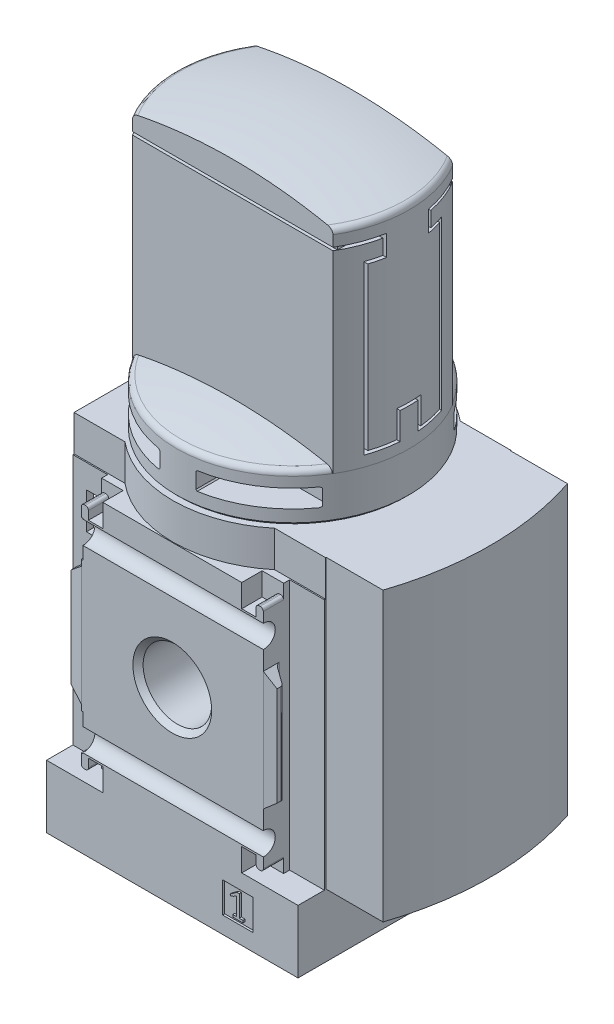
from build123d import *

# Parameters (mm, degrees)
BOSS_EXTRUDE1_DEPTH      = 48
BOSS_EXTRUDE2_DEPTH      = 20.1
BOSS_EXTRUDE2_DEPTH_BACK = 20.1
SKETCH2_W                = 42
SKETCH2_H                = 42
SKETCH3_W                = 42
SKETCH3_H                = 40.2
BOSS_EXTRUDE3_DEPTH      = 10.5
BOSS_EXTRUDE4_DEPTH      = 48
SKETCH7_W                = 5.1
SKETCH7_H                = 5.1
CUT_EXTRUDE1_DEPTH       = 0.35
SKETCH8_W                = 5.1
SKETCH8_H                = 5.1
CUT_EXTRUDE2_DEPTH       = 0.35
CUT_EXTRUDE3_DEPTH       = 25
CUT_EXTRUDE3_DEPTH_BACK  = 25
CUT_EXTRUDE4_DEPTH       = 25
CUT_EXTRUDE4_DEPTH_BACK  = 25
CUT_EXTRUDE5_DEPTH       = 3.4
CUT_EXTRUDE5_DEPTH_BACK  = 3.4
CUT_EXTRUDE6_DEPTH       = 3.4
CUT_EXTRUDE6_DEPTH_BACK  = 3.4
CUT_EXTRUDE7_DEPTH       = 3.4
CUT_EXTRUDE7_DEPTH_BACK  = 3.4
CUT_EXTRUDE8_DEPTH       = 3.4
CUT_EXTRUDE8_DEPTH_BACK  = 3.4
CUT_EXTRUDE9_DEPTH       = 21
CUT_EXTRUDE9_DEPTH_BACK  = 21
CUT_EXTRUDE10_DEPTH      = 21
CUT_EXTRUDE10_DEPTH_BACK = 21
CUT_EXTRUDE11_DEPTH      = 19.5
CUT_EXTRUDE11_DEPTH_BACK = 19.5
CUT_EXTRUDE12_DEPTH      = 10
CUT_EXTRUDE13_DEPTH      = 10
CUT_EXTRUDE14_DEPTH      = 10
CUT_EXTRUDE15_DEPTH      = 10
CUT_EXTRUDE16_DEPTH      = 20.5
SKETCH25_W               = 20
SKETCH25_H               = 0.5
CUT_EXTRUDE17_DEPTH      = 4.5
CUT_EXTRUDE18_DEPTH      = 22
CUT_EXTRUDE18_DEPTH_BACK = 22
SKETCH27_W               = 3.81
SKETCH27_H               = 6.07
CUT_EXTRUDE19_DEPTH      = 22
CUT_EXTRUDE19_DEPTH_BACK = 22
SKETCH28_W               = 3.81
SKETCH28_H               = 6.07
CUT_EXTRUDE20_DEPTH      = 11
CUT_EXTRUDE20_DEPTH_BACK = 11
SKETCH29_W               = 29
SKETCH29_H               = 37.9
BOSS_EXTRUDE5_DEPTH      = 19
BOSS_EXTRUDE5_DEPTH_BACK = 19
BOSS_EXTRUDE6_DEPTH      = 9
BOSS_EXTRUDE7_DEPTH      = 9
SKETCH33_R               = 3.05
BOSS_EXTRUDE8_DEPTH      = 5


with BuildPart() as part:
    # Sketch1 → Boss-Extrude1 (new body)
    with BuildSketch(Plane(origin=(0, 27, 0), x_dir=(1, 0, 0), z_dir=(0, 1, 0))):
        with BuildLine():
            Line((-21, -15.5), (-12.5, -15.5))
            ThreePointArc((-12.5, -15.5), (0, -20), (12.5, -15.5))
            Line((12.5, -15.5), (21, -15.5))
            Line((21, -15.5), (21, 15.5))
            Line((21, 15.5), (12.5, 15.5))
            ThreePointArc((12.5, 15.5), (0, 20), (-12.5, 15.5))
            Line((-12.5, 15.5), (-21, 15.5))
            Line((-21, 15.5), (-21, -15.5))
        make_face()
    extrude(amount=-BOSS_EXTRUDE1_DEPTH)

    # Sketch2 → Boss-Extrude2 (add, two sides: drawn at the far end of the back side and taken through both)
    with BuildSketch(Plane.XY.offset(-BOSS_EXTRUDE2_DEPTH_BACK)):
        Rectangle(SKETCH2_W, SKETCH2_H)
    extrude(amount=BOSS_EXTRUDE2_DEPTH + BOSS_EXTRUDE2_DEPTH_BACK)

    # Sketch3 → Boss-Extrude3 (add)
    with BuildSketch(Plane(origin=(0, -31.5, 0), x_dir=(1, 0, 0), z_dir=(0, 1, 0))):
        Rectangle(SKETCH3_W, SKETCH3_H)
    extrude(amount=BOSS_EXTRUDE3_DEPTH)

    # Sketch4 → Boss-Extrude4 (add)
    with BuildSketch(Plane(origin=(0, 27, 0), x_dir=(1, 0, 0), z_dir=(0, 1, 0))):
        with BuildLine():
            Line((20.9, -15.4), (30.5, -15.4))
            ThreePointArc((30.5, -15.4), (33, 0), (30.5, 15.4))
            Line((30.5, 15.4), (20.9, 15.4))
            Line((20.9, 15.4), (20.9, -15.4))
        make_face()
    extrude(amount=-BOSS_EXTRUDE4_DEPTH)

    # Sketch5 → Cut-Revolve1 (revolve, cut)
    with BuildSketch(Plane(origin=(0, 0, 0), x_dir=(0, 0, -1), z_dir=(1, 0, 0))):
        Polygon((-20.1, 0), (-20.1, 6.5785), (-19.244, 5.7225), (-7.799, 5.7225), (-6.943, 6.5785), (-6.943, 0), align=None)
    revolve(axis=Axis((0, 0, 6.943), (0, 0, 1)), mode=Mode.SUBTRACT)

    # Sketch6 → Cut-Revolve2 (revolve, cut)
    with BuildSketch(Plane(origin=(0, 0, 0), x_dir=(0, 0, -1), z_dir=(1, 0, 0))):
        Polygon((6.943, 0), (6.943, 6.5785), (7.799, 5.7225), (19.244, 5.7225), (20.1, 6.5785), (20.1, 0), align=None)
    revolve(axis=Axis((0, 0, -20.1), (0, 0, 1)), mode=Mode.SUBTRACT)

    # Sketch7 → Cut-Extrude1 (cut)
    with BuildSketch(Plane.XY.offset(20.1)):
        with Locations((10.95, -26.14)):
            Rectangle(SKETCH7_W, SKETCH7_H)
        Polygon((9.663200115, -25.02), (9.761292304, -25.275538889), (10.24, -25.062404491), (10.71, -24.78), (10.71, -27.76), (10.1, -27.76), (10.1, -28.14), (11.8, -28.14), (11.8, -27.76), (11.19, -27.76), (11.19, -24.21), (10.82, -24.21), align=None, mode=Mode.SUBTRACT)
    extrude(amount=-CUT_EXTRUDE1_DEPTH, mode=Mode.SUBTRACT)

    # Sketch8 → Cut-Extrude2 (cut)
    with BuildSketch(Plane.XY.offset(-20.1)):
        with Locations((-10.95, -26.14)):
            Rectangle(SKETCH8_W, SKETCH8_H)
        with BuildLine():
            Line((-12.03983262, -25.241503505), (-10.470570303, -27.482642356))
            ThreePointArc((-10.470570303, -27.482642356), (-10.463784424, -27.586174861), (-10.552485507, -27.64))
            Line((-10.552485507, -27.64), (-12.15, -27.64))
            Line((-12.15, -27.64), (-12.15, -28.14))
            Line((-12.15, -28.14), (-9.75, -28.14))
            Line((-9.75, -28.14), (-9.75, -27.64))
            Line((-9.75, -27.64), (-11.575165094, -25.033394109))
            ThreePointArc((-11.575165094, -25.033394109), (-11.592129791, -24.774562847), (-11.370377083, -24.64))
            Line((-11.370377083, -24.64), (-10.75, -24.64))
            ThreePointArc((-10.75, -24.64), (-10.396446609, -24.786446609), (-10.25, -25.14))
            Line((-10.25, -25.14), (-9.75, -25.14))
            ThreePointArc((-9.75, -25.14), (-10.042893219, -24.432893219), (-10.75, -24.14))
            Line((-10.75, -24.14), (-11.466426189, -24.14))
            ThreePointArc((-11.466426189, -24.14), (-12.087333772, -24.516775971), (-12.03983262, -25.241503505))
        make_face(mode=Mode.SUBTRACT)
    extrude(amount=CUT_EXTRUDE2_DEPTH, mode=Mode.SUBTRACT)

    # Sketch9 → Cut-Extrude3 (cut, two sides: drawn at the far end of the back side and taken through both)
    with BuildSketch(Plane(origin=(0, 0, 0), x_dir=(0, 0, -1), z_dir=(1, 0, 0)).offset(-CUT_EXTRUDE3_DEPTH_BACK)):
        with BuildLine():
            Line((21.9, -15), (21.9, 15))
            ThreePointArc((21.9, 15), (18.490033113, 16.153256259), (20.5, 13.166969722))
            Line((20.5, 13.166969722), (20.5, -13.166969722))
            ThreePointArc((20.5, -13.166969722), (18.490033113, -16.153256259), (21.9, -15))
        make_face()
    extrude(amount=CUT_EXTRUDE3_DEPTH + CUT_EXTRUDE3_DEPTH_BACK, mode=Mode.SUBTRACT)

    # Sketch10 → Cut-Extrude4 (cut, two sides: drawn at the far end of the back side and taken through both)
    with BuildSketch(Plane(origin=(0, 0, 0), x_dir=(0, 0, -1), z_dir=(1, 0, 0)).offset(-CUT_EXTRUDE4_DEPTH_BACK)):
        with BuildLine():
            Line((-21.9, 15), (-21.9, -15))
            ThreePointArc((-21.9, -15), (-18.490033113, -16.153256259), (-20.5, -13.166969722))
            Line((-20.5, -13.166969722), (-20.5, 13.166969722))
            ThreePointArc((-20.5, 13.166969722), (-18.490033113, 16.153256259), (-21.9, 15))
        make_face()
    extrude(amount=CUT_EXTRUDE4_DEPTH + CUT_EXTRUDE4_DEPTH_BACK, mode=Mode.SUBTRACT)

    # Sketch11 → Cut-Extrude5 (cut, two sides: drawn at the far end of the back side and taken through both)
    with BuildSketch(Plane.XY.offset(20.1).offset(-CUT_EXTRUDE5_DEPTH_BACK)):
        with BuildLine():
            Line((11.6, 21), (11.6, 17.2))
            Line((11.6, 17.2), (14, 17.2))
            Line((14, 17.2), (14, 18.6))
            ThreePointArc((14, 18.6), (14.146446609, 18.953553391), (14.5, 19.1))
            Line((14.5, 19.1), (14.7, 19.1))
            ThreePointArc((14.7, 19.1), (15.053553391, 18.953553391), (15.2, 18.6))
            Line((15.2, 18.6), (15.2, 9.95))
            Line((15.2, 9.95), (21.5, 4.663672324))
            Line((21.5, 4.663672324), (21.5, -4.663672324))
            Line((21.5, -4.663672324), (15.2, -9.95))
            Line((15.2, -9.95), (15.2, -18.6))
            ThreePointArc((15.2, -18.6), (15.053553391, -18.953553391), (14.7, -19.1))
            Line((14.7, -19.1), (14.5, -19.1))
            ThreePointArc((14.5, -19.1), (14.146446609, -18.953553391), (14, -18.6))
            Line((14, -18.6), (14, -17.2))
            Line((14, -17.2), (11.6, -17.2))
            Line((11.6, -17.2), (11.6, -21))
            Line((11.6, -21), (22, -21))
            Line((22, -21), (22, 21))
            Line((22, 21), (11.6, 21))
        make_face()
    extrude(amount=CUT_EXTRUDE5_DEPTH + CUT_EXTRUDE5_DEPTH_BACK, mode=Mode.SUBTRACT)

    # Sketch12 → Cut-Extrude6 (cut, two sides: drawn at the far end of the back side and taken through both)
    with BuildSketch(Plane.XY.offset(20.1).offset(-CUT_EXTRUDE6_DEPTH_BACK)):
        with BuildLine():
            Line((-22, -21), (-11.6, -21))
            Line((-11.6, -21), (-11.6, -17.2))
            Line((-11.6, -17.2), (-14, -17.2))
            Line((-14, -17.2), (-14, -18.6))
            ThreePointArc((-14, -18.6), (-14.146446609, -18.953553391), (-14.5, -19.1))
            Line((-14.5, -19.1), (-14.7, -19.1))
            ThreePointArc((-14.7, -19.1), (-15.053553391, -18.953553391), (-15.2, -18.6))
            Line((-15.2, -18.6), (-15.2, -9.95))
            Line((-15.2, -9.95), (-21.5, -4.663672324))
            Line((-21.5, -4.663672324), (-21.5, 4.663672324))
            Line((-21.5, 4.663672324), (-15.2, 9.95))
            Line((-15.2, 9.95), (-15.2, 18.6))
            ThreePointArc((-15.2, 18.6), (-15.053553391, 18.953553391), (-14.7, 19.1))
            Line((-14.7, 19.1), (-14.5, 19.1))
            ThreePointArc((-14.5, 19.1), (-14.146446609, 18.953553391), (-14, 18.6))
            Line((-14, 18.6), (-14, 17.2))
            Line((-14, 17.2), (-11.6, 17.2))
            Line((-11.6, 17.2), (-11.6, 21))
            Line((-11.6, 21), (-22, 21))
            Line((-22, 21), (-22, -21))
        make_face()
    extrude(amount=CUT_EXTRUDE6_DEPTH + CUT_EXTRUDE6_DEPTH_BACK, mode=Mode.SUBTRACT)

    # Sketch13 → Cut-Extrude7 (cut, two sides: drawn at the far end of the back side and taken through both)
    with BuildSketch(Plane.XY.offset(-20.1).offset(-CUT_EXTRUDE7_DEPTH_BACK)):
        with BuildLine():
            Line((11.6, 21), (11.6, 17.2))
            Line((11.6, 17.2), (14, 17.2))
            Line((14, 17.2), (14, 18.6))
            ThreePointArc((14, 18.6), (14.146446609, 18.953553391), (14.5, 19.1))
            Line((14.5, 19.1), (14.7, 19.1))
            ThreePointArc((14.7, 19.1), (15.053553391, 18.953553391), (15.2, 18.6))
            Line((15.2, 18.6), (15.2, 9.95))
            Line((15.2, 9.95), (21.5, 4.663672324))
            Line((21.5, 4.663672324), (21.5, -4.663672324))
            Line((21.5, -4.663672324), (15.2, -9.95))
            Line((15.2, -9.95), (15.2, -18.6))
            ThreePointArc((15.2, -18.6), (15.053553391, -18.953553391), (14.7, -19.1))
            Line((14.7, -19.1), (14.5, -19.1))
            ThreePointArc((14.5, -19.1), (14.146446609, -18.953553391), (14, -18.6))
            Line((14, -18.6), (14, -17.2))
            Line((14, -17.2), (11.6, -17.2))
            Line((11.6, -17.2), (11.6, -21))
            Line((11.6, -21), (22, -21))
            Line((22, -21), (22, 21))
            Line((22, 21), (11.6, 21))
        make_face()
    extrude(amount=CUT_EXTRUDE7_DEPTH + CUT_EXTRUDE7_DEPTH_BACK, mode=Mode.SUBTRACT)

    # Sketch14 → Cut-Extrude8 (cut, two sides: drawn at the far end of the back side and taken through both)
    with BuildSketch(Plane.XY.offset(-20.1).offset(-CUT_EXTRUDE8_DEPTH_BACK)):
        with BuildLine():
            Line((-22, -21), (-11.6, -21))
            Line((-11.6, -21), (-11.6, -17.2))
            Line((-11.6, -17.2), (-14, -17.2))
            Line((-14, -17.2), (-14, -18.6))
            ThreePointArc((-14, -18.6), (-14.146446609, -18.953553391), (-14.5, -19.1))
            Line((-14.5, -19.1), (-14.7, -19.1))
            ThreePointArc((-14.7, -19.1), (-15.053553391, -18.953553391), (-15.2, -18.6))
            Line((-15.2, -18.6), (-15.2, -9.95))
            Line((-15.2, -9.95), (-21.5, -4.663672324))
            Line((-21.5, -4.663672324), (-21.5, 4.663672324))
            Line((-21.5, 4.663672324), (-15.2, 9.95))
            Line((-15.2, 9.95), (-15.2, 18.6))
            ThreePointArc((-15.2, 18.6), (-15.053553391, 18.953553391), (-14.7, 19.1))
            Line((-14.7, 19.1), (-14.5, 19.1))
            ThreePointArc((-14.5, 19.1), (-14.146446609, 18.953553391), (-14, 18.6))
            Line((-14, 18.6), (-14, 17.2))
            Line((-14, 17.2), (-11.6, 17.2))
            Line((-11.6, 17.2), (-11.6, 21))
            Line((-11.6, 21), (-22, 21))
            Line((-22, 21), (-22, -21))
        make_face()
    extrude(amount=CUT_EXTRUDE8_DEPTH + CUT_EXTRUDE8_DEPTH_BACK, mode=Mode.SUBTRACT)

    # Sketch15 → Cut-Extrude9 (cut, two sides: drawn at the far end of the back side and taken through both)
    with BuildSketch(Plane(origin=(0, 0, 0), x_dir=(1, 0, 0), z_dir=(0, 1, 0)).offset(-CUT_EXTRUDE9_DEPTH_BACK)):
        with BuildLine():
            Line((-22.2, 25.1), (-22.2, 15.7))
            Line((-22.2, 15.7), (-15.2, 15.7))
            Line((-15.2, 15.7), (-15.2, 17.400104518))
            ThreePointArc((-15.2, 17.400104518), (-15.321561523, 17.82403993), (-15.649303083, 18.119139756))
            Line((-15.649303083, 18.119139756), (-16.919185573, 18.73850283))
            ThreePointArc((-16.919185573, 18.73850283), (-17.124024048, 18.922940221), (-17.2, 19.187899853))
            Line((-17.2, 19.187899853), (-17.2, 19.8))
            Line((-17.2, 19.8), (-15.2, 20.1))
            Line((-15.2, 20.1), (15.2, 20.1))
            Line((15.2, 20.1), (17.2, 19.8))
            Line((17.2, 19.8), (17.2, 19.187899853))
            ThreePointArc((17.2, 19.187899853), (17.124024048, 18.922940221), (16.919185573, 18.73850283))
            Line((16.919185573, 18.73850283), (15.649303083, 18.119139756))
            ThreePointArc((15.649303083, 18.119139756), (15.321561523, 17.82403993), (15.2, 17.400104518))
            Line((15.2, 17.400104518), (15.2, 15.7))
            Line((15.2, 15.7), (22.2, 15.7))
            Line((22.2, 15.7), (22.2, 25.1))
            Line((22.2, 25.1), (-22.2, 25.1))
        make_face()
    extrude(amount=CUT_EXTRUDE9_DEPTH + CUT_EXTRUDE9_DEPTH_BACK, mode=Mode.SUBTRACT)

    # Sketch16 → Cut-Extrude10 (cut, two sides: drawn at the far end of the back side and taken through both)
    with BuildSketch(Plane(origin=(0, 0, 0), x_dir=(1, 0, 0), z_dir=(0, 1, 0)).offset(-CUT_EXTRUDE10_DEPTH_BACK)):
        with BuildLine():
            Line((-22.2, -15.7), (-22.2, -25.1))
            Line((-22.2, -25.1), (22.2, -25.1))
            Line((22.2, -25.1), (22.2, -15.7))
            Line((22.2, -15.7), (15.2, -15.7))
            Line((15.2, -15.7), (15.2, -17.400104518))
            ThreePointArc((15.2, -17.400104518), (15.321561523, -17.82403993), (15.649303083, -18.119139756))
            Line((15.649303083, -18.119139756), (16.919185573, -18.73850283))
            ThreePointArc((16.919185573, -18.73850283), (17.124024048, -18.922940221), (17.2, -19.187899853))
            Line((17.2, -19.187899853), (17.2, -19.8))
            Line((17.2, -19.8), (15.2, -20.1))
            Line((15.2, -20.1), (-15.2, -20.1))
            Line((-15.2, -20.1), (-17.2, -19.8))
            Line((-17.2, -19.8), (-17.2, -19.187899853))
            ThreePointArc((-17.2, -19.187899853), (-17.124024048, -18.922940221), (-16.919185573, -18.73850283))
            Line((-16.919185573, -18.73850283), (-15.649303083, -18.119139756))
            ThreePointArc((-15.649303083, -18.119139756), (-15.321561523, -17.82403993), (-15.2, -17.400104518))
            Line((-15.2, -17.400104518), (-15.2, -15.7))
            Line((-15.2, -15.7), (-22.2, -15.7))
        make_face()
    extrude(amount=CUT_EXTRUDE10_DEPTH + CUT_EXTRUDE10_DEPTH_BACK, mode=Mode.SUBTRACT)

    # Sketch17 → Revolve1 (revolve)
    with BuildSketch(Plane.XY):
        with BuildLine():
            Line((19.5, 68.803320241), (19.5, 34.25))
            Line((19.5, 34.25), (18.5, 34.25))
            Line((18.5, 34.25), (18.5, 27))
            Line((18.5, 27), (0, 27))
            Line((0, 27), (0, 72))
            ThreePointArc((0, 72), (9.432891035, 71.441932043), (18.734177215, 69.775514168))
            ThreePointArc((18.734177215, 69.775514168), (19.285549876, 69.422118586), (19.5, 68.803320241))
        make_face()
    revolve(axis=Axis((0, 27, 0), (0, 1, 0)))

    # Sketch18 → Cut-Extrude11 (cut, two sides: drawn at the far end of the back side and taken through both)
    with BuildSketch(Plane(origin=(0, 0, 0), x_dir=(0, 0, -1), z_dir=(1, 0, 0)).offset(-CUT_EXTRUDE11_DEPTH_BACK)):
        Polygon((-30, 82), (-30, 27), (-10, 27), (-10, 66.5), (-9.5, 66.5), (-9.5, 67), (-10, 67), (-10, 72), (10, 72), (10, 67), (9.5, 67), (9.5, 66.5), (10, 66.5), (10, 27), (30, 27), (30, 82), align=None)
    extrude(amount=CUT_EXTRUDE11_DEPTH + CUT_EXTRUDE11_DEPTH_BACK, mode=Mode.SUBTRACT)

    # Sketch19 → Revolve2 (revolve)
    with BuildSketch(Plane.XY):
        with BuildLine():
            Line((19.4, 34.215226427), (19.4, 27.5))
            Line((19.4, 27.5), (18.9, 27))
            Line((18.9, 27), (0, 27))
            Line((0, 27), (0, 37.387887543))
            ThreePointArc((0, 37.387887543), (9.381179362, 36.835942735), (18.632911392, 35.187724388))
            ThreePointArc((18.632911392, 35.187724388), (19.185146927, 34.834535965), (19.4, 34.215226427))
        make_face()
    revolve(axis=Axis((0, 27, 0), (0, 1, 0)))

    # Sketch20 → Cut-Extrude12 (cut)
    with BuildSketch(Plane.XY.offset(20.1)):
        Polygon((3, 32.3), (3, 29.7), (3.2, 29.5), (15.8, 29.5), (16, 29.7), (16, 32.3), (15.8, 32.5), (3.2, 32.5), align=None)
    extrude(amount=-CUT_EXTRUDE12_DEPTH, mode=Mode.SUBTRACT)

    # Sketch21 → Cut-Extrude13 (cut)
    with BuildSketch(Plane.XY.offset(20.1)):
        Polygon((-16, 32.3), (-16, 29.7), (-15.8, 29.5), (-3.2, 29.5), (-3, 29.7), (-3, 32.3), (-3.2, 32.5), (-15.8, 32.5), align=None)
    extrude(amount=-CUT_EXTRUDE13_DEPTH, mode=Mode.SUBTRACT)

    # Sketch22 → Cut-Extrude14 (cut)
    with BuildSketch(Plane.XY.offset(-20.1)):
        Polygon((-16, 32.3), (-16, 29.7), (-15.8, 29.5), (-3.2, 29.5), (-3, 29.7), (-3, 32.3), (-3.2, 32.5), (-15.8, 32.5), align=None)
    extrude(amount=CUT_EXTRUDE14_DEPTH, mode=Mode.SUBTRACT)

    # Sketch23 → Cut-Extrude15 (cut)
    with BuildSketch(Plane.XY.offset(-20.1)):
        Polygon((3, 32.3), (3, 29.7), (3.2, 29.5), (15.8, 29.5), (16, 29.7), (16, 32.3), (15.8, 32.5), (3.2, 32.5), align=None)
    extrude(amount=CUT_EXTRUDE15_DEPTH, mode=Mode.SUBTRACT)

    # Sketch24 → Cut-Extrude16 (cut)
    with BuildSketch(Plane(origin=(37.5, 0, 0), x_dir=(0, 0, -1), z_dir=(1, 0, 0))):
        Polygon((-10, 66.5), (-4, 66.5), (-4, 64), (-6.5, 64), (-6.5, 36), (-1.5, 36), (-1.5, 40.5), (1.5, 40.5), (1.5, 36), (6.5, 36), (6.5, 64), (4, 64), (4, 66.5), (10, 66.5), (10, 67), (3.5, 67), (3.5, 63.5), (6, 63.5), (6, 36.5), (2, 36.5), (2, 41), (-2, 41), (-2, 36.5), (-6, 36.5), (-6, 63.5), (-3.5, 63.5), (-3.5, 67), (-10, 67), align=None)
    extrude(amount=-CUT_EXTRUDE16_DEPTH, mode=Mode.SUBTRACT)

    # Sketch25 → Cut-Extrude17 (cut)
    with BuildSketch(Plane(origin=(-21, 0, 0), x_dir=(0, 0, -1), z_dir=(1, 0, 0))):
        with Locations((0, 66.75)):
            Rectangle(SKETCH25_W, SKETCH25_H)
    extrude(amount=CUT_EXTRUDE17_DEPTH, mode=Mode.SUBTRACT)

    # Sketch26 → Cut-Revolve3 (revolve, cut)
    with BuildSketch(Plane.XY):
        Polygon((0, -18.343), (5.7225, -18.343), (5.7225, -30.644), (6.5785, -31.5), (0, -31.5), align=None)
    revolve(axis=Axis((0, -31.5, 0), (0, 1, 0)), mode=Mode.SUBTRACT)

    # Sketch27 → Cut-Extrude18 (cut, two sides: drawn at the far end of the back side and taken through both)
    with BuildSketch(Plane.XY.offset(-CUT_EXTRUDE18_DEPTH_BACK)):
        with Locations((-16.825, 14.005)):
            Rectangle(SKETCH27_W, SKETCH27_H)
    extrude(amount=CUT_EXTRUDE18_DEPTH + CUT_EXTRUDE18_DEPTH_BACK, mode=Mode.SUBTRACT)

    # Sketch28 → Cut-Extrude19 (cut, two sides: drawn at the far end of the back side and taken through both)
    with BuildSketch(Plane.XY.offset(-CUT_EXTRUDE19_DEPTH_BACK)):
        with Locations((-16.825, -13.995)):
            Rectangle(SKETCH28_W, SKETCH28_H)
    extrude(amount=CUT_EXTRUDE19_DEPTH + CUT_EXTRUDE19_DEPTH_BACK, mode=Mode.SUBTRACT)

    # Sketch29 → Cut-Extrude20 (cut, two sides: drawn at the far end of the back side and taken through both)
    with BuildSketch(Plane(origin=(-21, 0, 0), x_dir=(0, 0, -1), z_dir=(1, 0, 0)).offset(-CUT_EXTRUDE20_DEPTH_BACK)):
        Rectangle(SKETCH29_W, SKETCH29_H)
    extrude(amount=CUT_EXTRUDE20_DEPTH + CUT_EXTRUDE20_DEPTH_BACK, mode=Mode.SUBTRACT)

    # Sketch30 → Boss-Extrude5 (add, two sides: drawn at the far end of the back side and taken through both)
    with BuildSketch(Plane(origin=(0, 0, 0), x_dir=(1, 0, 0), z_dir=(0, 1, 0)).offset(-BOSS_EXTRUDE5_DEPTH_BACK)):
        with BuildLine():
            Line((-11.489125293, -14.5), (-10, -14.5))
            Line((-10, -14.5), (-10, 14.5))
            Line((-10, 14.5), (-11.489125293, 14.5))
            ThreePointArc((-11.489125293, 14.5), (-18.5, 0), (-11.489125293, -14.5))
        make_face()
    extrude(amount=BOSS_EXTRUDE5_DEPTH + BOSS_EXTRUDE5_DEPTH_BACK)

    # Sketch31 → Boss-Extrude6 (add)
    with BuildSketch(Plane(origin=(-19.9, 0, 0), x_dir=(0, 0, -1), z_dir=(1, 0, 0))):
        with BuildLine():
            Line((8.8, -21.3), (14.6, -21.3))
            Line((14.6, -21.3), (14.6, -17.1))
            Line((14.6, -17.1), (13.163330765, -17.1))
            ThreePointArc((13.163330765, -17.1), (10.799161363, -15.309186489), (8.8, -17.5))
            Line((8.8, -17.5), (8.8, -21.3))
        make_face()
    extrude(amount=BOSS_EXTRUDE6_DEPTH)

    # Sketch32 → Boss-Extrude7 (add)
    with BuildSketch(Plane(origin=(-19.9, 0, 0), x_dir=(0, 0, -1), z_dir=(1, 0, 0))):
        with BuildLine():
            Line((-14.6, 17.1), (-13.163330765, 17.1))
            ThreePointArc((-13.163330765, 17.1), (-10.799161363, 15.309186489), (-8.8, 17.5))
            Line((-8.8, 17.5), (-8.8, 21.3))
            Line((-8.8, 21.3), (-14.6, 21.3))
            Line((-14.6, 21.3), (-14.6, 17.1))
        make_face()
    extrude(amount=BOSS_EXTRUDE7_DEPTH)

    # Sketch33 → Boss-Extrude8 (add)
    with BuildSketch(Plane(origin=(-18, 0, 0), x_dir=(0, 0, -1), z_dir=(1, 0, 0))):
        with Locations((8.6, 6)):
            Circle(SKETCH33_R)
    extrude(amount=BOSS_EXTRUDE8_DEPTH)


solid = part.part
